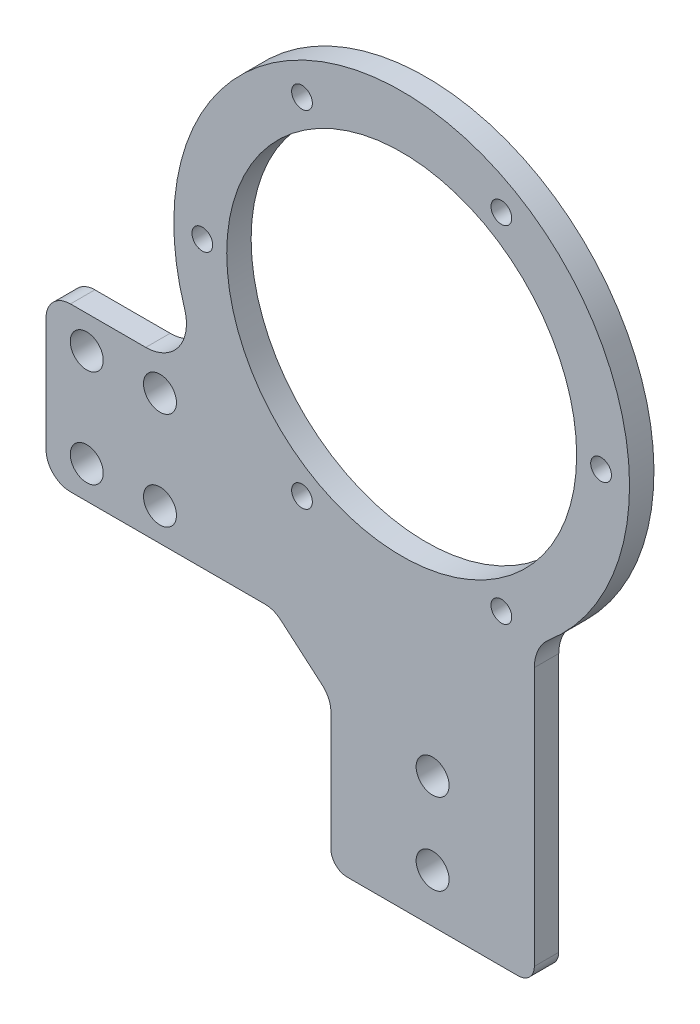
from build123d import *

# Parameters (mm, degrees)
EXTRUDE_1_DEPTH          = 3
SKETCH_2_R               = 28
EXTRUDE_2_DEPTH          = 3
SKETCH_3_R               = 21.5
CUT_EXTRUDE_1_DEPTH      = 3
FILLET_2_R               = 5
SKETCH_4_R               = 1.275
CUT_EXTRUDE_2_DEPTH      = 4
SKETCH_5_R               = 2.025
CUT_EXTRUDE_3_DEPTH      = 4
SKETCH_6_W               = 25
SKETCH_6_H               = 6
CUT_EXTRUDE_4_DEPTH      = 4
FILLET_3_R               = 2
SKETCH_8_R               = 2.025
CUT_EXTRUDE_5_DEPTH      = 10
SKETCH_9_R               = 2.025
CUT_EXTRUDE_6_DEPTH      = 1
CUT_EXTRUDE_6_DEPTH_BACK = 4
EXTRUDE_3_DEPTH          = 3
FILLET_4_R               = 3


with BuildPart() as part:
    # 草图1 → 凸台-拉伸1 (new body)
    with BuildSketch(Plane.XY):
        Polygon((-35, 0), (0, 0), (0, -30), (25, -30), (25, 20), (-35, 20), align=None)
    extrude(amount=EXTRUDE_1_DEPTH)

    # 草图2 → 凸台-拉伸2 (add)
    with BuildSketch(Plane(origin=(0, 0, 0), x_dir=(-1, 0, 0), z_dir=(0, 0, -1))):
        with Locations((-8.7, 35)):
            Circle(SKETCH_2_R)
    extrude(amount=-EXTRUDE_2_DEPTH)

    # 草图3 → 切除-拉伸1 (cut)
    with BuildSketch(Plane(origin=(0, 0, 0), x_dir=(-1, 0, 0), z_dir=(0, 0, -1))):
        with Locations((-8.7, 35)):
            Circle(SKETCH_3_R)
    extrude(amount=-CUT_EXTRUDE_1_DEPTH, mode=Mode.SUBTRACT)

    # 圆角2
    fillet_2_edges = [part.edges().sort_by_distance(p)[0] for p in [
        (25, 12.233577356, 1.5),
        (-14.943180835, 20, 1.5),
    ]]
    fillet(fillet_2_edges, radius=FILLET_2_R)

    # 草图4 → 切除-拉伸2 (cut, through all)
    with BuildSketch(Plane(origin=(0, 0, 0), x_dir=(-1, 0, 0), z_dir=(0, 0, -1))):
        with Locations((-33.2, 35)):
            Circle(SKETCH_4_R)
        with Locations((-20.95, 56.217622393)):
            Circle(SKETCH_4_R)
        with Locations((3.55, 56.217622393)):
            Circle(SKETCH_4_R)
        with Locations((15.8, 35)):
            Circle(SKETCH_4_R)
        with Locations((3.55, 13.782377607)):
            Circle(SKETCH_4_R)
        with Locations((-20.95, 13.782377607)):
            Circle(SKETCH_4_R)
    extrude(amount=-CUT_EXTRUDE_2_DEPTH, mode=Mode.SUBTRACT)

    # 草图5 → 切除-拉伸3 (cut, through all)
    with BuildSketch(Plane(origin=(0, 0, 0), x_dir=(-1, 0, 0), z_dir=(0, 0, -1))):
        with Locations((-12.5, -8)):
            Circle(SKETCH_5_R)
        with Locations((-12.5, -18)):
            Circle(SKETCH_5_R)
    extrude(amount=-CUT_EXTRUDE_3_DEPTH, mode=Mode.SUBTRACT)

    # 草图6 → 切除-拉伸4 (cut, through all)
    with BuildSketch(Plane(origin=(0, 0, 0), x_dir=(-1, 0, 0), z_dir=(0, 0, -1))):
        with Locations((-12.5, -27)):
            Rectangle(SKETCH_6_W, SKETCH_6_H)
    extrude(amount=-CUT_EXTRUDE_4_DEPTH, mode=Mode.SUBTRACT)

    # 圆角3
    fillet_3_edges = [part.edges().sort_by_distance(p)[0] for p in [
        (25, -24, 1.5),
        (0, -24, 1.5),
    ]]
    fillet(fillet_3_edges, radius=FILLET_3_R)

    # 草图8 → 切除-拉伸5 (cut)
    with BuildSketch(Plane.XY.offset(3)):
        with Locations((-30, 16)):
            Circle(SKETCH_8_R)
        with Locations((-30, 4)):
            Circle(SKETCH_8_R)
    extrude(amount=-CUT_EXTRUDE_5_DEPTH, mode=Mode.SUBTRACT)

    # 草图9 → 切除-拉伸6 (cut, two sides)
    with BuildSketch(Plane(origin=(0, 0, 0), x_dir=(-1, 0, 0), z_dir=(0, 0, -1))) as cut_extrude_6_sk:
        with Locations((21, 4)):
            Circle(SKETCH_9_R)
        with Locations((21, 16)):
            Circle(SKETCH_9_R)
    extrude(amount=CUT_EXTRUDE_6_DEPTH, mode=Mode.SUBTRACT)
    extrude(cut_extrude_6_sk.sketch, amount=-CUT_EXTRUDE_6_DEPTH_BACK, mode=Mode.SUBTRACT)

    # 草图10 → 凸台-拉伸3 (add)
    with BuildSketch(Plane(origin=(0, 0, 0), x_dir=(-1, 0, 0), z_dir=(0, 0, -1))):
        Polygon((0, -6), (7, 0), (0, 0), align=None)
    extrude(amount=-EXTRUDE_3_DEPTH)

    # 圆角4
    fillet_4_edges = [part.edges().sort_by_distance(p)[0] for p in [
        (-35, 20, 1.5),
        (-35, 0, 1.5),
        (-7, 0, 1.5),
        (0, -6, 1.5),
    ]]
    fillet(fillet_4_edges, radius=FILLET_4_R)


solid = part.part
